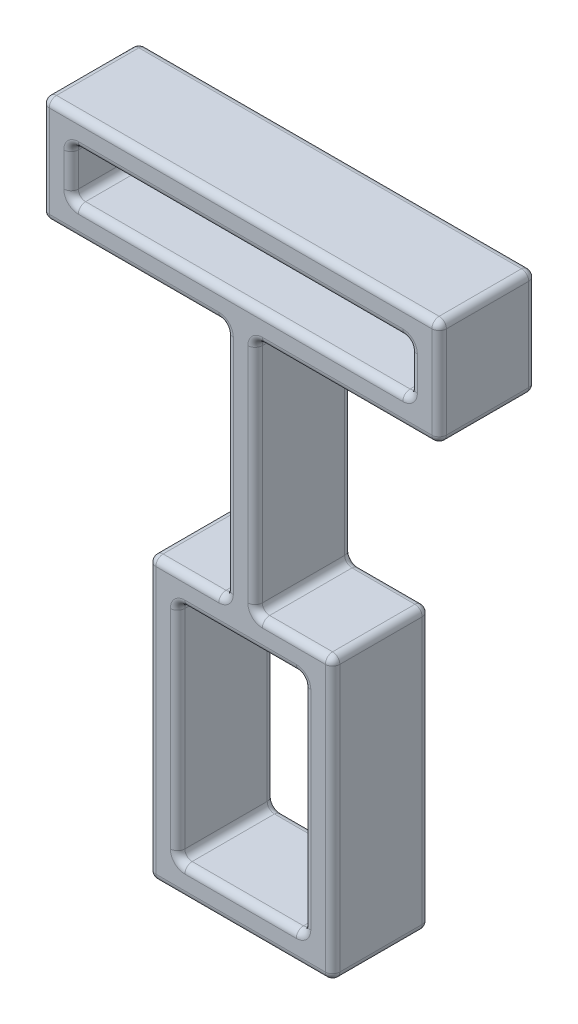
from build123d import *

# Parameters (mm, degrees)
SKETCH1_W           = 13
SKETCH1_H           = 23
SKETCH1_W_2         = 35
SKETCH1_H_2         = 5
BOSS_EXTRUDE1_DEPTH = 10
FILLET1_R           = 0.75


with BuildPart() as part:
    # Sketch1 → Boss-Extrude1 (new body)
    with BuildSketch(Plane.XY):
        Polygon((-20.5, 5.5), (20.5, 5.5), (20.5, -5.5), (1.5, -5.5), (1.5, -30), (9.5, -30), (9.5, -59), (-9.5, -59), (-9.5, -30), (-1.5, -30), (-1.5, -5.5), (-20.5, -5.5), align=None)
        with Locations((0, -44.5)):
            Rectangle(SKETCH1_W, SKETCH1_H, mode=Mode.SUBTRACT)
        Rectangle(SKETCH1_W_2, SKETCH1_H_2, mode=Mode.SUBTRACT)
    extrude(amount=BOSS_EXTRUDE1_DEPTH)

    # Fillet1
    fillet1_edges = [part.edges().sort_by_distance(p)[0] for p in [
        (0, 5.5, 0),
        (20.5, 0, 0),
        (-1.5, -17.75, 10),
        (11, -5.5, 0),
        (1.5, -17.75, 0),
        (5.5, -30, 0),
        (9.5, -44.5, 0),
        (0, -59, 0),
        (-9.5, -44.5, 0),
        (-5.5, -30, 0),
        (-1.5, -17.75, 0),
        (-11, -5.5, 0),
        (-20.5, 0, 0),
        (-5.5, -30, 10),
        (-20.5, 5.5, 5),
        (20.5, 5.5, 5),
        (20.5, -5.5, 5),
        (-9.5, -44.5, 10),
        (1.5, -5.5, 5),
        (1.5, -30, 5),
        (9.5, -30, 5),
        (9.5, -59, 5),
        (-9.5, -59, 5),
        (-9.5, -30, 5),
        (-1.5, -30, 5),
        (-1.5, -5.5, 5),
        (-20.5, -5.5, 5),
        (0, -59, 10),
        (9.5, -44.5, 10),
        (5.5, -30, 10),
        (-6.5, -44.5, 0),
        (-6.5, -33, 5),
        (0, -56, 0),
        (-6.5, -56, 5),
        (6.5, -44.5, 0),
        (6.5, -56, 5),
        (0, -33, 0),
        (6.5, -33, 5),
        (-6.5, -44.5, 10),
        (0, -56, 10),
        (6.5, -44.5, 10),
        (0, -33, 10),
        (1.5, -17.75, 10),
        (11, -5.5, 10),
        (20.5, 0, 10),
        (17.5, 0, 0),
        (17.5, -2.5, 5),
        (0, 2.5, 0),
        (17.5, 2.5, 5),
        (-17.5, 0, 0),
        (-17.5, 2.5, 5),
        (0, -2.5, 0),
        (-17.5, -2.5, 5),
        (17.5, 0, 10),
        (0, 2.5, 10),
        (-17.5, 0, 10),
        (0, 5.5, 10),
        (0, -2.5, 10),
        (-20.5, 0, 10),
        (-11, -5.5, 10),
    ]]
    fillet(fillet1_edges, radius=FILLET1_R)


solid = part.part
